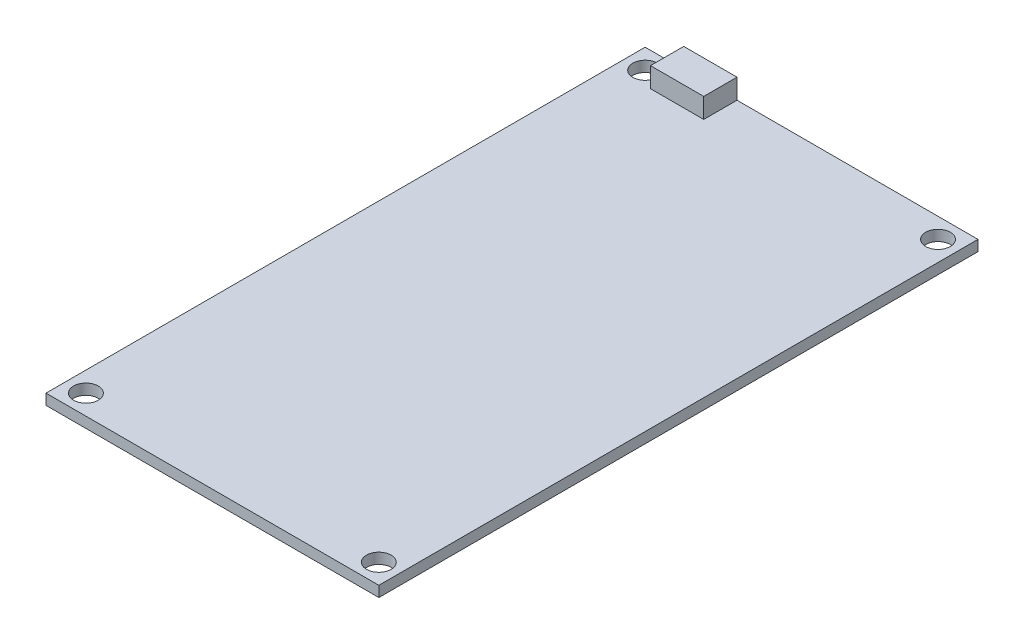
from build123d import *

# Parameters (mm, degrees)
SKETCH3_W           = 50
SKETCH3_H           = 90
BOSS_EXTRUDE2_DEPTH = 1.6
CUT_EXTRUDE1_REACH  = 3.6
SKETCH4_R           = 1.854
SKETCH5_W           = 8
SKETCH5_H           = 5
BOSS_EXTRUDE3_DEPTH = 3


with BuildPart() as part:
    # Sketch3 → Boss-Extrude2 (new body)
    with BuildSketch(Plane(origin=(0, 0, 0), x_dir=(1, 0, 0), z_dir=(0, 1, 0))):
        with Locations((25, -45)):
            Rectangle(SKETCH3_W, SKETCH3_H)
    extrude(amount=BOSS_EXTRUDE2_DEPTH)

    # Sketch4 → Cut-Extrude1 (cut, up to next)
    with BuildSketch(Plane(origin=(0, 1.6, 0), x_dir=(1, 0, 0), z_dir=(0, 1, 0)), mode=Mode.PRIVATE) as cut_extrude1_sk1:
        with Locations((3, -3.002549058)):
            Circle(SKETCH4_R)
    cut_extrude1_tool1 = extrude(cut_extrude1_sk1.sketch, amount=-CUT_EXTRUDE1_REACH, mode=Mode.PRIVATE) & part.part
    add(cut_extrude1_tool1.solids().sort_by_distance((3, 1.6, 3.002549))[0], mode=Mode.SUBTRACT)
    # Sketch4 → Cut-Extrude1 (cut, up to next)
    with BuildSketch(Plane(origin=(0, 1.6, 0), x_dir=(1, 0, 0), z_dir=(0, 1, 0)), mode=Mode.PRIVATE) as cut_extrude1_sk2:
        with Locations((47, -3.002549058)):
            Circle(SKETCH4_R)
    cut_extrude1_tool2 = extrude(cut_extrude1_sk2.sketch, amount=-CUT_EXTRUDE1_REACH, mode=Mode.PRIVATE) & part.part
    add(cut_extrude1_tool2.solids().sort_by_distance((47, 1.6, 3.002549))[0], mode=Mode.SUBTRACT)
    # Sketch4 → Cut-Extrude1 (cut, up to next)
    with BuildSketch(Plane(origin=(0, 1.6, 0), x_dir=(1, 0, 0), z_dir=(0, 1, 0)), mode=Mode.PRIVATE) as cut_extrude1_sk3:
        with Locations((47, -87.002549058)):
            Circle(SKETCH4_R)
    cut_extrude1_tool3 = extrude(cut_extrude1_sk3.sketch, amount=-CUT_EXTRUDE1_REACH, mode=Mode.PRIVATE) & part.part
    add(cut_extrude1_tool3.solids().sort_by_distance((47, 1.6, 87.002549))[0], mode=Mode.SUBTRACT)
    # Sketch4 → Cut-Extrude1 (cut, up to next)
    with BuildSketch(Plane(origin=(0, 1.6, 0), x_dir=(1, 0, 0), z_dir=(0, 1, 0)), mode=Mode.PRIVATE) as cut_extrude1_sk4:
        with Locations((3, -87.002549058)):
            Circle(SKETCH4_R)
    cut_extrude1_tool4 = extrude(cut_extrude1_sk4.sketch, amount=-CUT_EXTRUDE1_REACH, mode=Mode.PRIVATE) & part.part
    add(cut_extrude1_tool4.solids().sort_by_distance((3, 1.6, 87.002549))[0], mode=Mode.SUBTRACT)

    # Sketch5 → Boss-Extrude3 (add)
    with BuildSketch(Plane(origin=(0, 1.6, 0), x_dir=(1, 0, 0), z_dir=(0, 1, 0))):
        with Locations((9.8, -2.5)):
            Rectangle(SKETCH5_W, SKETCH5_H)
    extrude(amount=BOSS_EXTRUDE3_DEPTH)


solid = part.part
